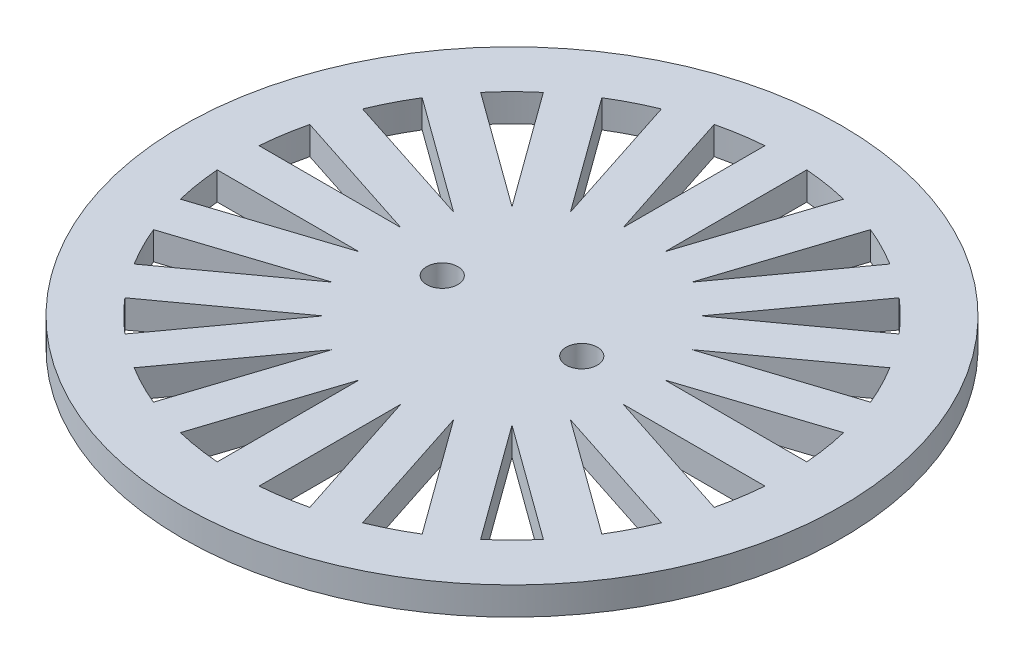
from build123d import *

# Parameters (mm, degrees)
SKETCH1_R           = 30
SKETCH1_R_2         = 1.4224
BOSS_EXTRUDE1_DEPTH = 2.54


with BuildPart() as part:
    # Sketch1 → Boss-Extrude1 (new body)
    with BuildSketch(Plane(origin=(0, 0, 0), x_dir=(1, 0, 0), z_dir=(0, 1, 0))):
        Circle(SKETCH1_R)
        with Locations((6.35, 0)):
            Circle(SKETCH1_R_2, mode=Mode.SUBTRACT)
        with Locations((-6.35, 0)):
            Circle(SKETCH1_R_2, mode=Mode.SUBTRACT)
        with BuildLine():
            Line((-1.905, 24.927313873), (-1.905, 12.027696635))
            Line((-1.905, 12.027696635), (-5.891200947, 24.295961666))
            ThreePointArc((-5.891200947, 24.295961666), (-3.910861632, 24.692208552), (-1.905, 24.927313873))
        make_face(mode=Mode.SUBTRACT)
        with BuildLine():
            Line((1.905, 24.927313873), (1.905, 12.027696635))
            Line((1.905, 12.027696635), (5.891200947, 24.295961666))
            ThreePointArc((5.891200947, 24.295961666), (3.910861632, 24.692208552), (1.905, 24.927313873))
        make_face(mode=Mode.SUBTRACT)
        with BuildLine():
            Line((9.514726274, 23.118606918), (5.528525327, 10.850341887))
            Line((5.528525327, 10.850341887), (13.110730099, 21.286351453))
            ThreePointArc((13.110730099, 21.286351453), (11.349762511, 22.275163139), (9.514726274, 23.118606918))
        make_face(mode=Mode.SUBTRACT)
        with BuildLine():
            Line((16.193084848, 19.046889641), (8.610880076, 8.610880076))
            Line((8.610880076, 8.610880076), (19.046889641, 16.193084848))
            ThreePointArc((19.046889641, 16.193084848), (17.677669557, 17.677669557), (16.193084848, 19.046889641))
        make_face(mode=Mode.SUBTRACT)
        with BuildLine():
            Line((21.286351453, 13.110730099), (10.850341887, 5.528525327))
            Line((10.850341887, 5.528525327), (23.118606918, 9.514726274))
            ThreePointArc((23.118606918, 9.514726274), (22.275163139, 11.349762511), (21.286351453, 13.110730099))
        make_face(mode=Mode.SUBTRACT)
        with BuildLine():
            Line((24.295961666, 5.891200947), (12.027696635, 1.905))
            Line((12.027696635, 1.905), (24.927313873, 1.905))
            ThreePointArc((24.927313873, 1.905), (24.692208552, 3.910861632), (24.295961666, 5.891200947))
        make_face(mode=Mode.SUBTRACT)
        with BuildLine():
            Line((24.927313873, -1.905), (12.027696635, -1.905))
            Line((12.027696635, -1.905), (24.295961666, -5.891200947))
            ThreePointArc((24.295961666, -5.891200947), (24.692208552, -3.910861632), (24.927313873, -1.905))
        make_face(mode=Mode.SUBTRACT)
        with BuildLine():
            Line((23.118606918, -9.514726274), (10.850341887, -5.528525327))
            Line((10.850341887, -5.528525327), (21.286351453, -13.110730099))
            ThreePointArc((21.286351453, -13.110730099), (22.275163139, -11.349762511), (23.118606918, -9.514726274))
        make_face(mode=Mode.SUBTRACT)
        with BuildLine():
            Line((19.046889641, -16.193084848), (8.610880076, -8.610880076))
            Line((8.610880076, -8.610880076), (16.193084848, -19.046889641))
            ThreePointArc((16.193084848, -19.046889641), (17.677669557, -17.677669557), (19.046889641, -16.193084848))
        make_face(mode=Mode.SUBTRACT)
        with BuildLine():
            Line((13.110730099, -21.286351453), (5.528525327, -10.850341887))
            Line((5.528525327, -10.850341887), (9.514726274, -23.118606918))
            ThreePointArc((9.514726274, -23.118606918), (11.349762511, -22.275163139), (13.110730099, -21.286351453))
        make_face(mode=Mode.SUBTRACT)
        with BuildLine():
            Line((5.891200947, -24.295961666), (1.905, -12.027696635))
            Line((1.905, -12.027696635), (1.905, -24.927313873))
            ThreePointArc((1.905, -24.927313873), (3.910861632, -24.692208552), (5.891200947, -24.295961666))
        make_face(mode=Mode.SUBTRACT)
        with BuildLine():
            Line((-1.905, -24.927313873), (-1.905, -12.027696635))
            Line((-1.905, -12.027696635), (-5.891200947, -24.295961666))
            ThreePointArc((-5.891200947, -24.295961666), (-3.910861632, -24.692208552), (-1.905, -24.927313873))
        make_face(mode=Mode.SUBTRACT)
        with BuildLine():
            Line((-9.514726274, -23.118606918), (-5.528525327, -10.850341887))
            Line((-5.528525327, -10.850341887), (-13.110730099, -21.286351453))
            ThreePointArc((-13.110730099, -21.286351453), (-11.349762511, -22.275163139), (-9.514726274, -23.118606918))
        make_face(mode=Mode.SUBTRACT)
        with BuildLine():
            Line((-16.193084848, -19.046889641), (-8.610880076, -8.610880076))
            Line((-8.610880076, -8.610880076), (-19.046889641, -16.193084848))
            ThreePointArc((-19.046889641, -16.193084848), (-17.677669557, -17.677669557), (-16.193084848, -19.046889641))
        make_face(mode=Mode.SUBTRACT)
        with BuildLine():
            Line((-21.286351453, -13.110730099), (-10.850341887, -5.528525327))
            Line((-10.850341887, -5.528525327), (-23.118606918, -9.514726274))
            ThreePointArc((-23.118606918, -9.514726274), (-22.275163139, -11.349762511), (-21.286351453, -13.110730099))
        make_face(mode=Mode.SUBTRACT)
        with BuildLine():
            Line((-24.295961666, -5.891200947), (-12.027696635, -1.905))
            Line((-12.027696635, -1.905), (-24.927313873, -1.905))
            ThreePointArc((-24.927313873, -1.905), (-24.692208552, -3.910861632), (-24.295961666, -5.891200947))
        make_face(mode=Mode.SUBTRACT)
        with BuildLine():
            Line((-24.927313873, 1.905), (-12.027696635, 1.905))
            Line((-12.027696635, 1.905), (-24.295961666, 5.891200947))
            ThreePointArc((-24.295961666, 5.891200947), (-24.692208552, 3.910861632), (-24.927313873, 1.905))
        make_face(mode=Mode.SUBTRACT)
        with BuildLine():
            Line((-23.118606918, 9.514726274), (-10.850341887, 5.528525327))
            Line((-10.850341887, 5.528525327), (-21.286351453, 13.110730099))
            ThreePointArc((-21.286351453, 13.110730099), (-22.275163139, 11.349762511), (-23.118606918, 9.514726274))
        make_face(mode=Mode.SUBTRACT)
        with BuildLine():
            Line((-19.046889641, 16.193084848), (-8.610880076, 8.610880076))
            Line((-8.610880076, 8.610880076), (-16.193084848, 19.046889641))
            ThreePointArc((-16.193084848, 19.046889641), (-17.677669557, 17.677669557), (-19.046889641, 16.193084848))
        make_face(mode=Mode.SUBTRACT)
        with BuildLine():
            Line((-13.110730099, 21.286351453), (-5.528525327, 10.850341887))
            Line((-5.528525327, 10.850341887), (-9.514726274, 23.118606918))
            ThreePointArc((-9.514726274, 23.118606918), (-11.349762511, 22.275163139), (-13.110730099, 21.286351453))
        make_face(mode=Mode.SUBTRACT)
    extrude(amount=BOSS_EXTRUDE1_DEPTH)


solid = part.part
